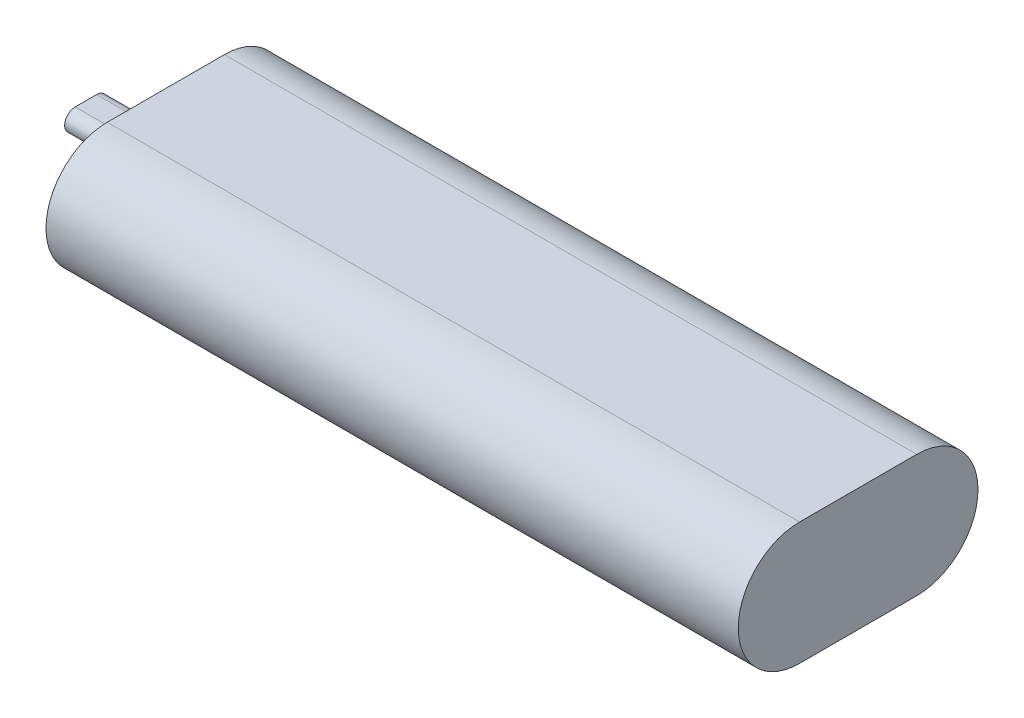
from build123d import *

# Parameters (mm, degrees)
BOSS_EXTRUDE1_DEPTH      = 65
BOSS_EXTRUDE1_DEPTH_BACK = 65
BOSS_EXTRUDE2_DEPTH      = 15


with BuildPart() as part:
    # Sketch1 → Boss-Extrude1 (new, two sides: drawn at the far end of the back side and taken through both)
    with BuildSketch(Plane(origin=(0, 0, 0), x_dir=(0, 0, -1), z_dir=(1, 0, 0)).offset(-BOSS_EXTRUDE1_DEPTH_BACK)):
        with BuildLine():
            Line((-11, 11.5), (11, 11.5))
            ThreePointArc((11, 11.5), (22.5, 0), (11, -11.5))
            Line((11, -11.5), (-11, -11.5))
            ThreePointArc((-11, -11.5), (-22.5, 0), (-11, 11.5))
        make_face()
    extrude(amount=BOSS_EXTRUDE1_DEPTH + BOSS_EXTRUDE1_DEPTH_BACK)

    # Sketch2 → Boss-Extrude2 (add)
    with BuildSketch(Plane.ZY.offset(65)):
        with BuildLine():
            Line((-2, 2), (2, 2))
            ThreePointArc((2, 2), (4, 0), (2, -2))
            Line((2, -2), (-2, -2))
            ThreePointArc((-2, -2), (-4, 0), (-2, 2))
        make_face()
    extrude(amount=BOSS_EXTRUDE2_DEPTH)


solid = part.part
